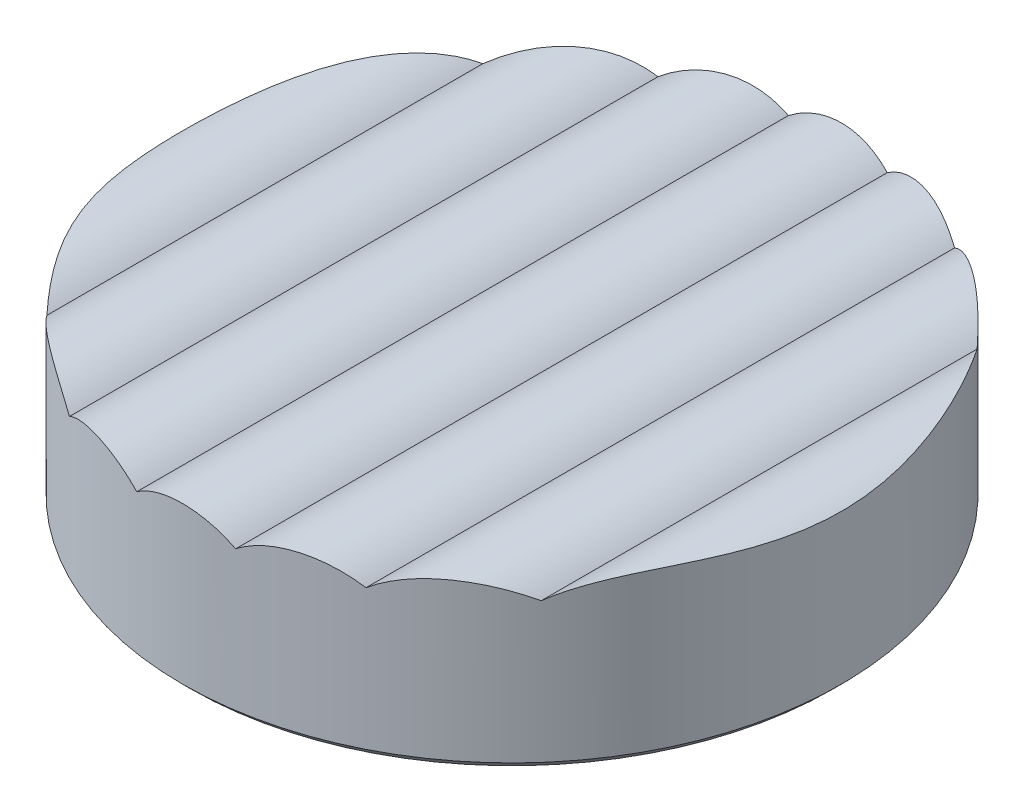
from build123d import *

# Parameters (mm, degrees)
SKETCH_1_R          = 4
EXTRUDE_1_DEPTH     = 2
CUT_EXTRUDE_1_DEPTH = 4
CHAMFER_1_SIZE      = 0.1


with BuildPart() as part:
    # 草图1 → 凸台-拉伸1 (new body)
    with BuildSketch(Plane(origin=(0, 0, 0), x_dir=(1, 0, 0), z_dir=(0, 1, 0))):
        Circle(SKETCH_1_R)
    extrude(amount=EXTRUDE_1_DEPTH)

    # 草图2 → 切除-拉伸1 (cut, symmetric)
    with BuildSketch(Plane.XY):
        with BuildLine():
            Line((-4.460903823, 1.508767734), (-4.68289812, 3.453905247))
            Line((-4.68289812, 3.453905247), (4.900344987, 2.697866633))
            Line((4.900344987, 2.697866633), (4.2, 1.8))
            ThreePointArc((4.2, 1.8), (3.6, 2), (3, 1.8))
            ThreePointArc((3, 1.8), (2.4, 2), (1.8, 1.8))
            ThreePointArc((1.8, 1.8), (1.2, 2), (0.6, 1.8))
            ThreePointArc((0.6, 1.8), (0, 2), (-0.6, 1.8))
            ThreePointArc((-0.6, 1.8), (-1.2, 2), (-1.8, 1.8))
            ThreePointArc((-1.8, 1.8), (-2.4, 2), (-3, 1.8))
            ThreePointArc((-3, 1.8), (-3.79550386, 1.980702932), (-4.460903823, 1.508767734))
        make_face()
    extrude(amount=CUT_EXTRUDE_1_DEPTH, both=True, mode=Mode.SUBTRACT)

    # 倒角1
    chamfer_1_edges = [part.edges().sort_by_distance(p)[0] for p in [
        (-4, 0, 0),
    ]]
    chamfer(chamfer_1_edges, length=CHAMFER_1_SIZE)


solid = part.part
